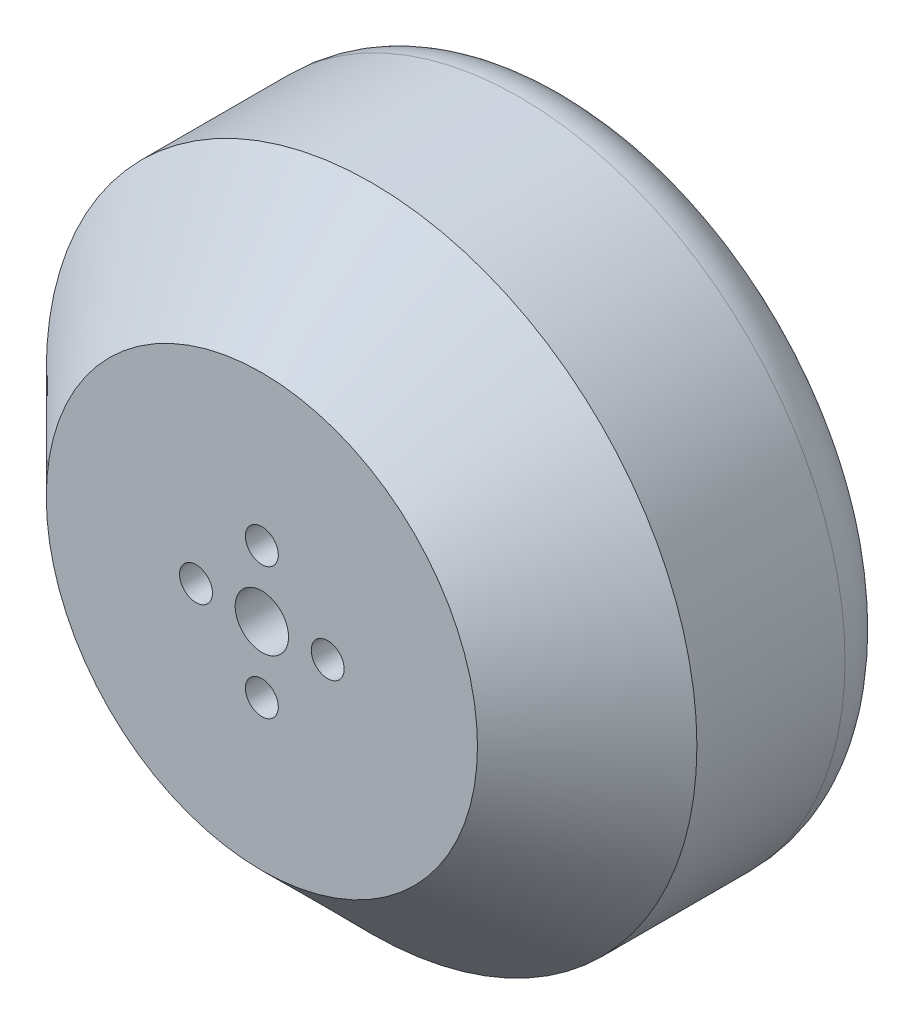
from build123d import *

# Parameters (mm, degrees)
SKETCH1_R           = 29.65
BOSS_EXTRUDE1_DEPTH = 28.5
CHAMFER1_SIZE       = 10
FILLET1_R           = 5
SKETCH2_R           = 1.5
SKETCH2_R_2         = 2.429720262
CUT_EXTRUDE1_DEPTH  = 9.5
SKETCH3_R           = 1.5
CUT_EXTRUDE2_DEPTH  = 9.5


with BuildPart() as part:
    # Sketch1 → Boss-Extrude1 (new body)
    with BuildSketch(Plane.XY):
        with Locations((-37.247490996, 0)):
            Circle(SKETCH1_R)
    extrude(amount=BOSS_EXTRUDE1_DEPTH)

    # Chamfer1
    chamfer1_edges = [part.edges().sort_by_distance(p)[0] for p in [
        (-66.897490996, 0, 28.5),
    ]]
    chamfer(chamfer1_edges, length=CHAMFER1_SIZE)

    # Fillet1
    fillet1_edges = [part.edges().sort_by_distance(p)[0] for p in [
        (-66.897490996, 0, 0),
    ]]
    fillet(fillet1_edges, radius=FILLET1_R)

    # Sketch2 → Cut-Extrude1 (cut)
    with BuildSketch(Plane.XY.offset(28.5)):
        with Locations((-37.247490996, 6)):
            Circle(SKETCH2_R)
        with Locations((-43.247490996, 0)):
            Circle(SKETCH2_R)
        with Locations((-37.247490996, -6)):
            Circle(SKETCH2_R)
        with Locations((-31.247490996, 0)):
            Circle(SKETCH2_R)
        with Locations((-37.247490996, 0)):
            Circle(SKETCH2_R_2)
    extrude(amount=-CUT_EXTRUDE1_DEPTH, mode=Mode.SUBTRACT)

    # Sketch3 → Cut-Extrude2 (cut)
    with BuildSketch(Plane(origin=(0, 0, 0), x_dir=(-1, 0, 0), z_dir=(0, 0, -1))):
        with Locations((37.247490996, 12.5)):
            Circle(SKETCH3_R)
        with Locations((49.747490996, 0)):
            Circle(SKETCH3_R)
        with Locations((24.761374027, 0.588967782)):
            Circle(SKETCH3_R)
        with Locations((37.247490996, -12.5)):
            Circle(SKETCH3_R)
    extrude(amount=-CUT_EXTRUDE2_DEPTH, mode=Mode.SUBTRACT)


solid = part.part
